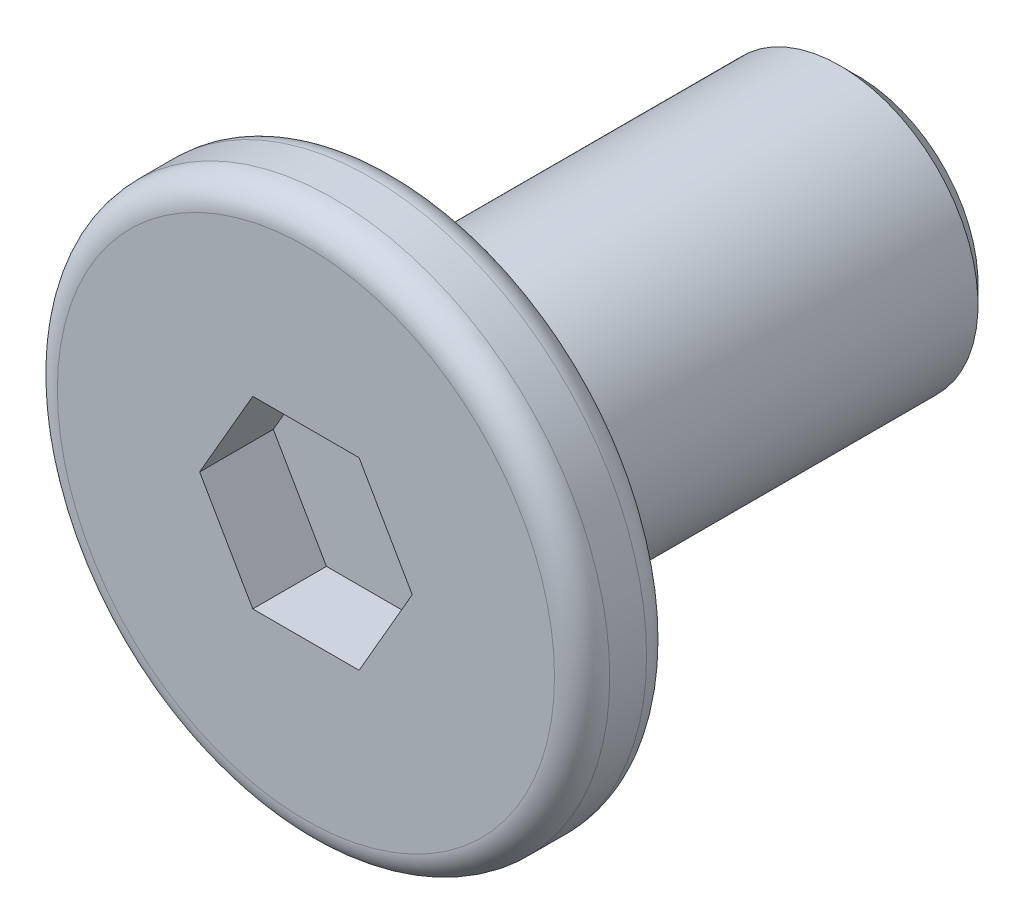
from build123d import *

# Parameters (mm, degrees)
SKETCH_1_R          = 3
EXTRUDE_1_DEPTH     = 0.5
SKETCH_2_R          = 1.5
EXTRUDE_2_DEPTH     = 5
CHAMFER_1_SIZE      = 0.2
CUT_EXTRUDE_1_DEPTH = 0.8
FILLET_2_R          = 0.3


with BuildPart() as part:
    # 草图1 → 凸台-拉伸1 (new body, symmetric)
    with BuildSketch(Plane.XY):
        Circle(SKETCH_1_R)
    extrude(amount=EXTRUDE_1_DEPTH, both=True)

    # 草图2 → 凸台-拉伸2 (add)
    with BuildSketch(Plane(origin=(0, 0, -0.5), x_dir=(-1, 0, 0), z_dir=(0, 0, -1))):
        Circle(SKETCH_2_R)
    extrude(amount=EXTRUDE_2_DEPTH)

    # 倒角1
    chamfer_1_edges = [part.edges().sort_by_distance(p)[0] for p in [
        (1.5, 0, -5.5),
    ]]
    chamfer(chamfer_1_edges, length=CHAMFER_1_SIZE)

    # 草图3 → 切除-拉伸1 (cut)
    with BuildSketch(Plane.XY.offset(0.5)):
        Polygon((1.154700538, 0), (0.577350269, 1), (-0.577350269, 1), (-1.154700538, 0), (-0.577350269, -1), (0.577350269, -1), align=None)
    extrude(amount=-CUT_EXTRUDE_1_DEPTH, mode=Mode.SUBTRACT)

    # 圆角2
    fillet_2_edges = [part.edges().sort_by_distance(p)[0] for p in [
        (-3, 0, -0.5),
        (-3, 0, 0.5),
    ]]
    fillet(fillet_2_edges, radius=FILLET_2_R)


solid = part.part
